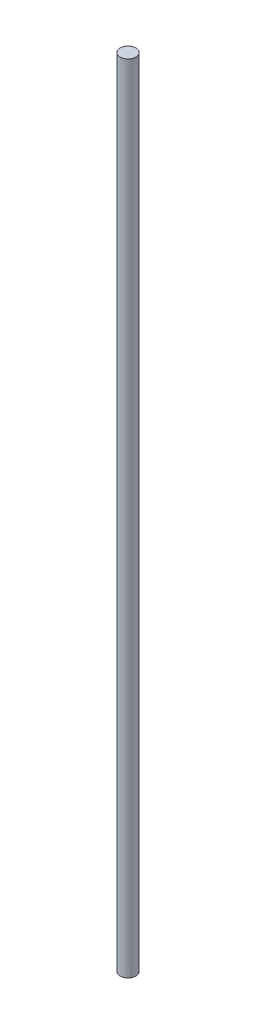
from build123d import *

# Parameters (mm, degrees)
SKETCH1_R           = 1.5
BOSS_EXTRUDE1_DEPTH = 150


with BuildPart() as part:
    # Sketch1 → Boss-Extrude1 (new body)
    with BuildSketch(Plane(origin=(0, 0, 0), x_dir=(1, 0, 0), z_dir=(0, 1, 0))):
        Circle(SKETCH1_R)
    extrude(amount=BOSS_EXTRUDE1_DEPTH)


solid = part.part
